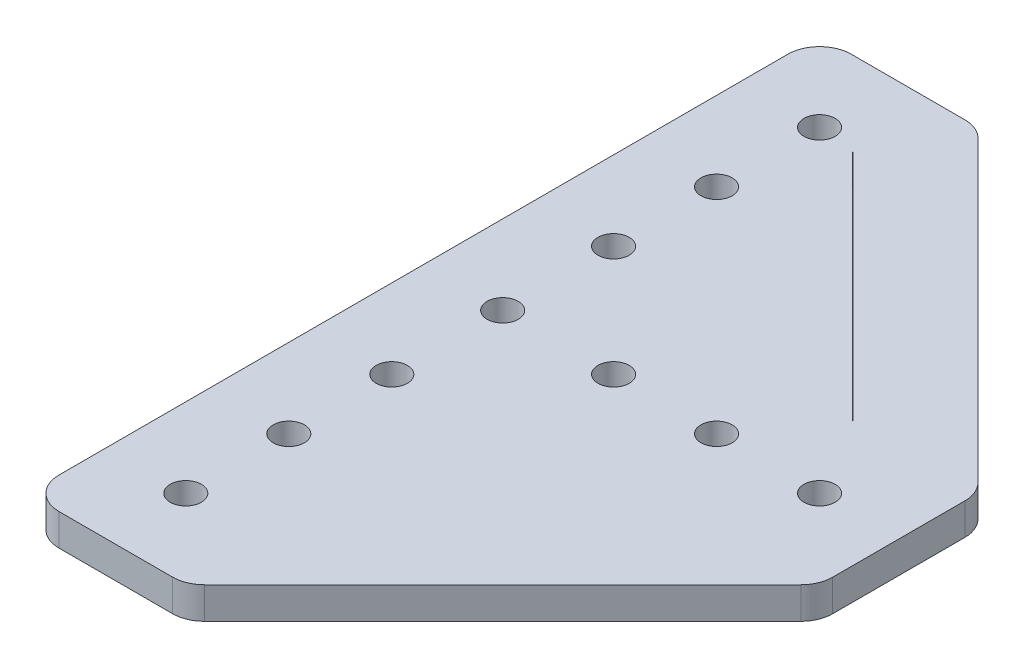
from build123d import *

# Parameters (mm, degrees)
SKETCH1_R           = 2.5
BOSS_EXTRUDE1_DEPTH = 5.08
FILLET1_R           = 5.08
FILLET2_R           = 5.08
CUT_EXTRUDE1_DEPTH  = 6.08


with BuildPart() as part:
    # Sketch1 → Boss-Extrude1 (new body)
    with BuildSketch(Plane(origin=(0, 0, 0), x_dir=(1, 0, 0), z_dir=(0, 1, 0))):
        Polygon((0, 0), (0, 76.2), (25.4, 76.2), (76.2, 25.4), (76.2, 0), align=None)
        with Locations((12.7, 63.5)):
            Circle(SKETCH1_R, mode=Mode.SUBTRACT)
        with Locations((63.5, 12.7)):
            Circle(SKETCH1_R, mode=Mode.SUBTRACT)
        with Locations((12.7, 46.99)):
            Circle(SKETCH1_R, mode=Mode.SUBTRACT)
        with Locations((12.7, 30.48)):
            Circle(SKETCH1_R, mode=Mode.SUBTRACT)
        with Locations((46.99, 12.7)):
            Circle(SKETCH1_R, mode=Mode.SUBTRACT)
        with Locations((30.48, 12.7)):
            Circle(SKETCH1_R, mode=Mode.SUBTRACT)
        with Locations((12.7, 12.7)):
            Circle(SKETCH1_R, mode=Mode.SUBTRACT)
    extrude(amount=BOSS_EXTRUDE1_DEPTH)

    # Fillet1
    fillet1_edges = [part.edges().sort_by_distance(p)[0] for p in [
        (0, 2.54, 0),
    ]]
    fillet(fillet1_edges, radius=FILLET1_R)

    # Fillet2
    fillet2_edges = [part.edges().sort_by_distance(p)[0] for p in [
        (0, 2.54, -76.2),
        (25.4, 2.54, -76.2),
        (76.2, 2.54, -25.4),
        (76.2, 2.54, 0),
    ]]
    fillet(fillet2_edges, radius=FILLET2_R)

    # Sketch2 → Cut-Extrude1 (cut, through all)
    with BuildSketch(Plane(origin=(0, 5.08, 0), x_dir=(1, 0, 0), z_dir=(0, 1, 0))):
        with BuildLine():
            Line((18.765620134, 62.732842611), (62.732842611, 18.765620134))
            ThreePointArc((62.732842611, 18.765620134), (62.746984747, 18.765620134), (62.746984747, 18.77976227))
            Line((62.746984747, 18.77976227), (18.77976227, 62.746984747))
            ThreePointArc((18.77976227, 62.746984747), (18.765620134, 62.746984747), (18.765620134, 62.732842611))
        make_face()
        with BuildLine():
            Line((18.763824083, 41.796641641), (41.796641641, 18.763824083))
            ThreePointArc((41.796641641, 18.763824083), (41.800233744, 18.763824083), (41.800233744, 18.767416186))
            Line((41.800233744, 18.767416186), (18.767416186, 41.800233744))
            ThreePointArc((18.767416186, 41.800233744), (18.763824083, 41.800233744), (18.763824083, 41.796641641))
        make_face()
        with BuildLine():
            Line((24.444358625, 18.548492515), (18.548492515, 24.444358625))
            ThreePointArc((18.548492515, 24.444358625), (18.544900412, 24.444358625), (18.544900412, 24.440766523))
            Line((18.544900412, 24.440766523), (24.440766523, 18.544900412))
            ThreePointArc((24.440766523, 18.544900412), (24.444358625, 18.544900412), (24.444358625, 18.548492515))
        make_face()
    extrude(amount=-CUT_EXTRUDE1_DEPTH, mode=Mode.SUBTRACT)

    # Mirror1: part across plane


with BuildPart() as part_1:
    add(part.part)
    add(part.part.mirror(Plane.XY.offset(-12.7)))


solid = part_1.part
